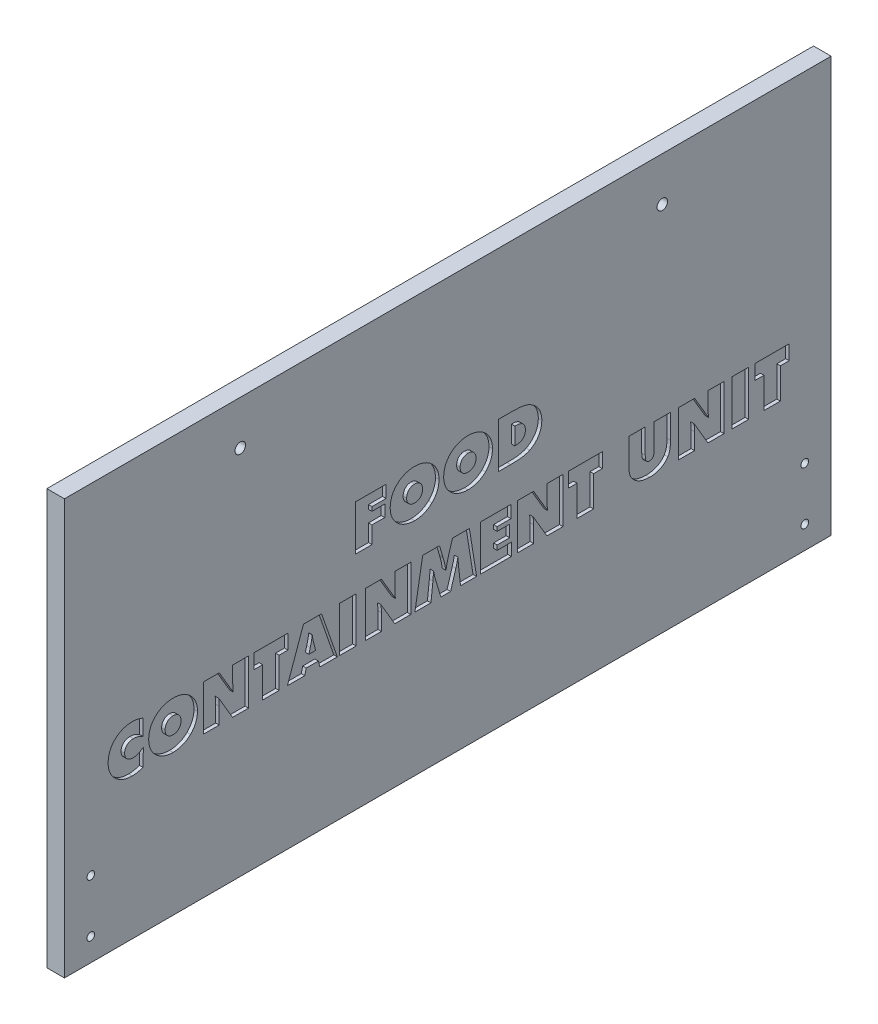
from build123d import *

# Parameters (mm, degrees)
SKETCH2_W           = 218
SKETCH2_H           = 118
BOSS_EXTRUDE1_DEPTH = 5
SKETCH15_W          = 4.678314393
SKETCH15_H          = 12.865364583
SKETCH15_W_2        = 4.678314394
CUT_EXTRUDE2_DEPTH  = 1
SKETCH16_R          = 1.5
CUT_EXTRUDE3_DEPTH  = 6
SKETCH18_R          = 1.1
CUT_EXTRUDE4_DEPTH  = 6


with BuildPart() as part:
    # Sketch2 → Boss-Extrude1 (new body)
    with BuildSketch(Plane(origin=(0, 0, 0), x_dir=(0, 0, -1), z_dir=(1, 0, 0))):
        with Locations((109, 59)):
            Rectangle(SKETCH2_W, SKETCH2_H)
    extrude(amount=-BOSS_EXTRUDE1_DEPTH)

    # Sketch15 → Cut-Extrude2 (cut)
    with BuildSketch(Plane(origin=(0, 0, 0), x_dir=(0, 0, -1), z_dir=(1, 0, 0))):
        Polygon((82.768022863, 63), (82.768022863, 75.865364583), (91.456321023, 75.865364583), (91.456321023, 72.356628788), (87.446337256, 72.356628788), (87.446337256, 71.187050189), (91.075163712, 71.187050189), (91.075163712, 67.845397051), (87.446337256, 67.845397051), (87.446337256, 63), align=None)
        with BuildLine():
            add(Edge.make_bspline(
                [(106.493760146, 69.51622362), (106.487889321, 69.286166725), (106.476319485, 68.832785682), (106.380049047, 68.165119304), (106.220241186, 67.522470312), (105.998561141, 66.905476911), (105.714845608, 66.318127193), (105.373461826, 65.761618233), (104.97359612, 65.235670347), (104.665317852, 64.917591564), (104.509653595, 64.756978564)],
                knots=[0, 0, 0, 0, 0.000689928, 0.001359664, 0.002018804, 0.002673665, 0.003322877, 0.003972109, 0.004629505, 0.00530004, 0.00530004, 0.00530004, 0.00530004], degree=3))
            add(Edge.make_bspline(
                [(104.509653595, 64.756978564), (104.343794855, 64.607146639), (104.013324874, 64.308609743), (103.463974377, 63.925256227), (102.881963855, 63.592029448), (102.263715365, 63.318769156), (101.618407496, 63.100352432), (100.948122927, 62.948680029), (100.258055409, 62.85014639), (99.79077784, 62.838701677), (99.554608551, 62.832917343)],
                knots=[0, 0, 0, 0, 0.000669981, 0.001334922, 0.002004893, 0.002679238, 0.003359506, 0.004045357, 0.004738364, 0.005446548, 0.005446548, 0.005446548, 0.005446548], degree=3))
            add(Edge.make_bspline(
                [(99.554608551, 62.832917343), (99.315825652, 62.838630414), (98.845067713, 62.849893673), (98.150668759, 62.948692446), (97.478609405, 63.100120415), (96.831806893, 63.31820776), (96.215403513, 63.594655562), (95.632456717, 63.928785339), (95.082035331, 64.316644898), (94.750519119, 64.620117589), (94.583899507, 64.772642563)],
                knots=[0, 0, 0, 0, 0.000716008, 0.001411603, 0.002099997, 0.002780265, 0.003455676, 0.00412338, 0.004793472, 0.005470567, 0.005470567, 0.005470567, 0.005470567], degree=3))
            add(Edge.make_bspline(
                [(94.583899507, 64.772642563), (94.428829669, 64.929518221), (94.121769646, 65.24015402), (93.72785182, 65.760396239), (93.38791736, 66.310103251), (93.111041023, 66.895423228), (92.892830026, 67.511043196), (92.740854373, 68.156314025), (92.642974081, 68.827499043), (92.631646879, 69.284399132), (92.625899621, 69.51622362)],
                knots=[0, 0, 0, 0, 0.000661133, 0.001309136, 0.001952553, 0.002597155, 0.003247803, 0.00390824, 0.004583146, 0.00527829, 0.00527829, 0.00527829, 0.00527829], degree=3))
            add(Edge.make_bspline(
                [(92.625899621, 69.51622362), (92.631592317, 69.748925208), (92.642791324, 70.206709502), (92.741184085, 70.879532208), (92.892686754, 71.526644383), (93.111705332, 72.14534985), (93.387077456, 72.734875153), (93.728089988, 73.28743303), (94.120185577, 73.810185112), (94.428608827, 74.119652349), (94.583899507, 74.275468676)],
                knots=[0, 0, 0, 0, 0.000697752, 0.001372658, 0.002035634, 0.002688744, 0.003338066, 0.003983708, 0.004633785, 0.005293024, 0.005293024, 0.005293024, 0.005293024], degree=3))
            add(Edge.make_bspline(
                [(94.583899507, 74.275468676), (94.749892089, 74.425941251), (95.080056817, 74.725236172), (95.625260744, 75.113248593), (96.207274967, 75.442165559), (96.823164711, 75.717705316), (97.470101698, 75.934199312), (98.14423723, 76.087892544), (98.841874393, 76.181425205), (99.315008472, 76.193443637), (99.554608551, 76.199529897)],
                knots=[0, 0, 0, 0, 0.000671693, 0.001336019, 0.002002429, 0.002674391, 0.003357134, 0.004045528, 0.004745951, 0.005464568, 0.005464568, 0.005464568, 0.005464568], degree=3))
            add(Edge.make_bspline(
                [(99.554608551, 76.199529897), (99.794212076, 76.193453274), (100.26735296, 76.181453873), (100.964940357, 76.087782046), (101.638454655, 75.934787704), (102.284718896, 75.716529065), (102.90202166, 75.442438224), (103.486782878, 75.112438687), (104.036695118, 74.72618663), (104.368985772, 74.426086802), (104.53576026, 74.275468676)],
                knots=[0, 0, 0, 0, 0.000718616, 0.001419039, 0.002107434, 0.002787702, 0.003462048, 0.00413073, 0.00479931, 0.005472974, 0.005472974, 0.005472974, 0.005472974], degree=3))
            add(Edge.make_bspline(
                [(104.53576026, 74.275468676), (104.688719178, 74.117394048), (104.992459293, 73.803495347), (105.388184874, 73.283091238), (105.722948179, 72.725894556), (106.003275883, 72.137952601), (106.223548511, 71.519585005), (106.379577438, 70.873913846), (106.47634869, 70.203151246), (106.487906659, 69.747159044), (106.493760146, 69.51622362)],
                knots=[0, 0, 0, 0, 0.000659466, 0.001309543, 0.001956061, 0.0026065, 0.003260481, 0.003921531, 0.004596438, 0.005288973, 0.005288973, 0.005288973, 0.005288973], degree=3))
        make_face()
        with BuildLine():
            add(Edge.make_bspline(
                [(99.565051217, 67.177066423), (99.647799432, 67.179219272), (99.809454138, 67.18342502), (100.045609876, 67.211937497), (100.269515412, 67.261716953), (100.48028781, 67.331866139), (100.679175719, 67.421562591), (100.865385443, 67.532176896), (101.040250116, 67.661841922), (101.199171287, 67.81263448), (101.346589751, 67.975321173), (101.471130531, 68.156127714), (101.576691739, 68.349953026), (101.665411896, 68.554893587), (101.733922226, 68.773589191), (101.780026912, 69.005573674), (101.809137906, 69.250068594), (101.813318263, 69.417805006), (101.815445752, 69.503170288)],
                knots=[0, 0, 0, 0, 0.000248233, 0.000484941, 0.000712324, 0.000935227, 0.001150207, 0.001365567, 0.00158382, 0.001801775, 0.002021831, 0.002241267, 0.002458581, 0.002683113, 0.002910181, 0.003144676, 0.003391754, 0.003647812, 0.003647812, 0.003647812, 0.003647812], degree=3))
            add(Edge.make_bspline(
                [(101.815445752, 69.503170288), (101.813314017, 69.589403162), (101.80912469, 69.75886971), (101.780060558, 70.005989775), (101.733770752, 70.240479219), (101.666191139, 70.461325604), (101.575143655, 70.667736065), (101.472863517, 70.865097807), (101.345661283, 71.046834046), (101.199229816, 71.211829059), (101.041172097, 71.36559243), (100.864509436, 71.494509154), (100.680003221, 71.608740123), (100.480219467, 71.69799943), (100.269160044, 71.767347863), (100.046009228, 71.821408202), (99.809398903, 71.848774841), (99.647780731, 71.853144212), (99.565051217, 71.855380817)],
                knots=[0, 0, 0, 0, 0.000258667, 0.000508337, 0.000745391, 0.000974952, 0.001199484, 0.001421391, 0.001640826, 0.001862841, 0.002082587, 0.002300839, 0.00251754, 0.00273252, 0.002955423, 0.00318339, 0.003420098, 0.003668331, 0.003668331, 0.003668331, 0.003668331], degree=3))
            add(Edge.make_bspline(
                [(99.565051217, 71.855380817), (99.482255189, 71.853570221), (99.320396713, 71.850030674), (99.083957409, 71.81659059), (98.859397191, 71.769322236), (98.647388151, 71.69651973), (98.446711114, 71.606975877), (98.25936681, 71.492328259), (98.084461443, 71.359270339), (97.923106465, 71.207589528), (97.775480811, 71.041394303), (97.651769645, 70.857188655), (97.542232795, 70.66361142), (97.457911313, 70.454723938), (97.384676963, 70.235953944), (97.340437113, 70.00232693), (97.310136756, 69.757202664), (97.306225016, 69.58942415), (97.304214015, 69.503170288)],
                knots=[0, 0, 0, 0, 0.000248233, 0.000485272, 0.000715204, 0.000935631, 0.001156445, 0.001373146, 0.00159297, 0.001814615, 0.002036629, 0.002258213, 0.002479073, 0.002702586, 0.002932932, 0.003169986, 0.00341447, 0.003673137, 0.003673137, 0.003673137, 0.003673137], degree=3))
            add(Edge.make_bspline(
                [(97.304214015, 69.503170288), (97.306311458, 69.417794459), (97.310432778, 69.250037323), (97.33996743, 69.005691119), (97.384618385, 68.772918264), (97.458525193, 68.556192396), (97.541551375, 68.348456487), (97.651885927, 68.156966784), (97.775520887, 67.975301399), (97.923175635, 67.811745813), (98.084529504, 67.662651083), (98.259466146, 67.532247889), (98.446789538, 67.420050858), (98.647982591, 67.33377499), (98.8593516, 67.260561667), (99.083756197, 67.212427162), (99.32061927, 67.183321352), (99.482293174, 67.179184173), (99.565051217, 67.177066423)],
                knots=[0, 0, 0, 0, 0.000256058, 0.000503136, 0.000737631, 0.000965493, 0.001189006, 0.001407586, 0.001627022, 0.001847078, 0.002066948, 0.002285201, 0.002500561, 0.002720307, 0.002940735, 0.003170666, 0.003407374, 0.003655607, 0.003655607, 0.003655607, 0.003655607], degree=3))
        make_face(mode=Mode.SUBTRACT)
        with BuildLine():
            add(Edge.make_bspline(
                [(121.698281926, 69.51622362), (121.692411102, 69.286166725), (121.680841265, 68.832785682), (121.584570828, 68.165119304), (121.424762967, 67.522470312), (121.203082922, 66.905476911), (120.919367388, 66.318127193), (120.577983606, 65.761618233), (120.1781179, 65.235670347), (119.869839633, 64.917591564), (119.714175375, 64.756978564)],
                knots=[0, 0, 0, 0, 0.000689928, 0.001359664, 0.002018804, 0.002673665, 0.003322877, 0.003972109, 0.004629505, 0.00530004, 0.00530004, 0.00530004, 0.00530004], degree=3))
            add(Edge.make_bspline(
                [(119.714175375, 64.756978564), (119.548316636, 64.607146639), (119.217846655, 64.308609743), (118.668496158, 63.925256227), (118.086485636, 63.592029448), (117.468237145, 63.318769156), (116.822929276, 63.100352432), (116.152644708, 62.948680029), (115.462577189, 62.85014639), (114.99529962, 62.838701677), (114.759130331, 62.832917343)],
                knots=[0, 0, 0, 0, 0.000669981, 0.001334922, 0.002004893, 0.002679238, 0.003359506, 0.004045357, 0.004738364, 0.005446548, 0.005446548, 0.005446548, 0.005446548], degree=3))
            add(Edge.make_bspline(
                [(114.759130331, 62.832917343), (114.520347433, 62.838630414), (114.049589493, 62.849893673), (113.355190539, 62.948692446), (112.683131186, 63.100120415), (112.036328673, 63.31820776), (111.419925293, 63.594655562), (110.836978497, 63.928785339), (110.286557112, 64.316644898), (109.955040899, 64.620117589), (109.788421287, 64.772642563)],
                knots=[0, 0, 0, 0, 0.000716008, 0.001411603, 0.002099997, 0.002780265, 0.003455676, 0.00412338, 0.004793472, 0.005470567, 0.005470567, 0.005470567, 0.005470567], degree=3))
            add(Edge.make_bspline(
                [(109.788421287, 64.772642563), (109.63335145, 64.929518221), (109.326291426, 65.24015402), (108.9323736, 65.760396239), (108.592439141, 66.310103251), (108.315562803, 66.895423228), (108.097351806, 67.511043196), (107.945376153, 68.156314025), (107.847495861, 68.827499043), (107.83616866, 69.284399132), (107.830421402, 69.51622362)],
                knots=[0, 0, 0, 0, 0.000661133, 0.001309136, 0.001952553, 0.002597155, 0.003247803, 0.00390824, 0.004583146, 0.00527829, 0.00527829, 0.00527829, 0.00527829], degree=3))
            add(Edge.make_bspline(
                [(107.830421402, 69.51622362), (107.836114097, 69.748925208), (107.847313104, 70.206709502), (107.945705865, 70.879532208), (108.097208534, 71.526644383), (108.316227113, 72.14534985), (108.591599236, 72.734875153), (108.932611769, 73.28743303), (109.324707358, 73.810185112), (109.633130607, 74.119652349), (109.788421287, 74.275468676)],
                knots=[0, 0, 0, 0, 0.000697752, 0.001372658, 0.002035634, 0.002688744, 0.003338066, 0.003983708, 0.004633785, 0.005293024, 0.005293024, 0.005293024, 0.005293024], degree=3))
            add(Edge.make_bspline(
                [(109.788421287, 74.275468676), (109.954413869, 74.425941251), (110.284578597, 74.725236172), (110.829782524, 75.113248593), (111.411796748, 75.442165559), (112.027686491, 75.717705316), (112.674623479, 75.934199312), (113.34875901, 76.087892544), (114.046396174, 76.181425205), (114.519530252, 76.193443637), (114.759130331, 76.199529897)],
                knots=[0, 0, 0, 0, 0.000671693, 0.001336019, 0.002002429, 0.002674391, 0.003357134, 0.004045528, 0.004745951, 0.005464568, 0.005464568, 0.005464568, 0.005464568], degree=3))
            add(Edge.make_bspline(
                [(114.759130331, 76.199529897), (114.998733856, 76.193453274), (115.47187474, 76.181453873), (116.169462137, 76.087782046), (116.842976435, 75.934787704), (117.489240676, 75.716529065), (118.106543441, 75.442438224), (118.691304658, 75.112438687), (119.241216898, 74.72618663), (119.573507552, 74.426086802), (119.740282041, 74.275468676)],
                knots=[0, 0, 0, 0, 0.000718616, 0.001419039, 0.002107434, 0.002787702, 0.003462048, 0.00413073, 0.00479931, 0.005472974, 0.005472974, 0.005472974, 0.005472974], degree=3))
            add(Edge.make_bspline(
                [(119.740282041, 74.275468676), (119.893240958, 74.117394048), (120.196981073, 73.803495347), (120.592706654, 73.283091238), (120.927469959, 72.725894556), (121.207797663, 72.137952601), (121.428070291, 71.519585005), (121.584099218, 70.873913846), (121.680870471, 70.203151246), (121.692428439, 69.747159044), (121.698281926, 69.51622362)],
                knots=[0, 0, 0, 0, 0.000659466, 0.001309543, 0.001956061, 0.0026065, 0.003260481, 0.003921531, 0.004596438, 0.005288973, 0.005288973, 0.005288973, 0.005288973], degree=3))
        make_face()
        with BuildLine():
            add(Edge.make_bspline(
                [(114.769572997, 67.177066423), (114.852321212, 67.179219272), (115.013975918, 67.18342502), (115.250131656, 67.211937497), (115.474037192, 67.261716953), (115.68480959, 67.331866139), (115.8836975, 67.421562591), (116.069907224, 67.532176896), (116.244771897, 67.661841922), (116.403693068, 67.81263448), (116.551111532, 67.975321173), (116.675652311, 68.156127714), (116.781213519, 68.349953026), (116.869933677, 68.554893587), (116.938444006, 68.773589191), (116.984548692, 69.005573674), (117.013659686, 69.250068594), (117.017840043, 69.417805006), (117.019967532, 69.503170288)],
                knots=[0, 0, 0, 0, 0.000248233, 0.000484941, 0.000712324, 0.000935227, 0.001150207, 0.001365567, 0.00158382, 0.001801775, 0.002021831, 0.002241267, 0.002458581, 0.002683113, 0.002910181, 0.003144676, 0.003391754, 0.003647812, 0.003647812, 0.003647812, 0.003647812], degree=3))
            add(Edge.make_bspline(
                [(117.019967532, 69.503170288), (117.017835798, 69.589403162), (117.01364647, 69.75886971), (116.984582338, 70.005989775), (116.938292532, 70.240479219), (116.87071292, 70.461325604), (116.779665436, 70.667736065), (116.677385298, 70.865097807), (116.550183063, 71.046834046), (116.403751597, 71.211829059), (116.245693877, 71.36559243), (116.069031217, 71.494509154), (115.884525002, 71.608740123), (115.684741247, 71.69799943), (115.473681824, 71.767347863), (115.250531008, 71.821408202), (115.013920683, 71.848774841), (114.852302511, 71.853144212), (114.769572997, 71.855380817)],
                knots=[0, 0, 0, 0, 0.000258667, 0.000508337, 0.000745391, 0.000974952, 0.001199484, 0.001421391, 0.001640826, 0.001862841, 0.002082587, 0.002300839, 0.00251754, 0.00273252, 0.002955423, 0.00318339, 0.003420098, 0.003668331, 0.003668331, 0.003668331, 0.003668331], degree=3))
            add(Edge.make_bspline(
                [(114.769572997, 71.855380817), (114.686776969, 71.853570221), (114.524918493, 71.850030674), (114.288479189, 71.81659059), (114.063918972, 71.769322236), (113.851909931, 71.69651973), (113.651232894, 71.606975877), (113.463888591, 71.492328259), (113.288983223, 71.359270339), (113.127628245, 71.207589528), (112.980002591, 71.041394303), (112.856291425, 70.857188655), (112.746754576, 70.66361142), (112.662433093, 70.454723938), (112.589198743, 70.235953944), (112.544958893, 70.00232693), (112.514658537, 69.757202664), (112.510746796, 69.58942415), (112.508735795, 69.503170288)],
                knots=[0, 0, 0, 0, 0.000248233, 0.000485272, 0.000715204, 0.000935631, 0.001156445, 0.001373146, 0.00159297, 0.001814615, 0.002036629, 0.002258213, 0.002479073, 0.002702586, 0.002932932, 0.003169986, 0.00341447, 0.003673137, 0.003673137, 0.003673137, 0.003673137], degree=3))
            add(Edge.make_bspline(
                [(112.508735795, 69.503170288), (112.510833239, 69.417794459), (112.514954558, 69.250037323), (112.544489211, 69.005691119), (112.589140165, 68.772918264), (112.663046973, 68.556192396), (112.746073155, 68.348456487), (112.856407707, 68.156966784), (112.980042668, 67.975301399), (113.127697415, 67.811745813), (113.289051284, 67.662651083), (113.463987926, 67.532247889), (113.651311319, 67.420050858), (113.852504371, 67.33377499), (114.06387338, 67.260561667), (114.288277977, 67.212427162), (114.52514105, 67.183321352), (114.686814954, 67.179184173), (114.769572997, 67.177066423)],
                knots=[0, 0, 0, 0, 0.000256058, 0.000503136, 0.000737631, 0.000965493, 0.001189006, 0.001407586, 0.001627022, 0.001847078, 0.002066948, 0.002285201, 0.002500561, 0.002720307, 0.002940735, 0.003170666, 0.003407374, 0.003655607, 0.003655607, 0.003655607, 0.003655607], degree=3))
        make_face(mode=Mode.SUBTRACT)
        with BuildLine():
            Line((123.369108496, 63), (123.369108496, 75.865364583))
            Line((123.369108496, 75.865364583), (127.18590294, 75.865364583))
            add(Edge.make_bspline(
                [(127.18590294, 75.865364583), (127.472241498, 75.862781969), (128.023410201, 75.857810736), (128.81770109, 75.822292351), (129.546629394, 75.759986173), (130.211805001, 75.675992058), (130.815267125, 75.564260768), (131.359465221, 75.427781504), (131.846709674, 75.263825378), (132.14123951, 75.12321947), (132.281923976, 75.056057964)],
                knots=[0, 0, 0, 0, 0.000859008, 0.001653492, 0.002384558, 0.00305324, 0.003664097, 0.004224467, 0.004735525, 0.005202863, 0.005202863, 0.005202863, 0.005202863], degree=3))
            add(Edge.make_bspline(
                [(132.281923976, 75.056057964), (132.4179073, 74.982223316), (132.687150158, 74.836032953), (133.066847325, 74.586813977), (133.424030295, 74.321612714), (133.758892842, 74.04183022), (134.065127901, 73.738176885), (134.349923761, 73.421086053), (134.610398963, 73.084597238), (134.844053733, 72.730553213), (135.053088705, 72.361516076), (135.23793027, 71.980758784), (135.38713655, 71.583547005), (135.517564236, 71.177702657), (135.612883307, 70.756305923), (135.683489374, 70.323989906), (135.726499349, 69.878239871), (135.730964595, 69.577233576), (135.733225108, 69.424850292)],
                knots=[0, 0, 0, 0, 0.000464038, 0.000918782, 0.001361033, 0.001798256, 0.002226548, 0.002653654, 0.003076106, 0.003501861, 0.003925087, 0.004347789, 0.00477008, 0.005196962, 0.005625692, 0.006064757, 0.006510532, 0.006967585, 0.006967585, 0.006967585, 0.006967585], degree=3))
            add(Edge.make_bspline(
                [(135.733225108, 69.424850292), (135.730915304, 69.273341462), (135.726339757, 68.97321394), (135.683945147, 68.529995561), (135.612438699, 68.099525378), (135.517142437, 67.681129045), (135.390767011, 67.275922579), (135.239014132, 66.882185793), (135.059660341, 66.501019671), (134.849046373, 66.134831562), (134.614833455, 65.783070462), (134.355947801, 65.447068468), (134.06952298, 65.131364076), (133.761773446, 64.830374554), (133.428093154, 64.547490471), (133.070154058, 64.280946842), (132.686388105, 64.032316916), (132.416043936, 63.884212602), (132.27931331, 63.809306619)],
                knots=[0, 0, 0, 0, 0.000454443, 0.000900218, 0.001334131, 0.001762861, 0.002186473, 0.002606328, 0.003027908, 0.003448866, 0.003872446, 0.004294898, 0.00472006, 0.005150219, 0.005585449, 0.006031353, 0.006488287, 0.006955881, 0.006955881, 0.006955881, 0.006955881], degree=3))
            add(Edge.make_bspline(
                [(132.27931331, 63.809306619), (132.135104039, 63.741382575), (131.834198887, 63.599653163), (131.339803238, 63.431953566), (130.790617236, 63.297119597), (130.297181582, 63.203517375), (129.868436708, 63.146310453), (129.514117047, 63.107752372), (129.132996416, 63.072860209), (128.725395701, 63.049364597), (128.292240414, 63.022687579), (127.831612814, 63.013337529), (127.344352542, 63.000308266), (127.010129602, 63.000104517), (126.838684293, 63)],
                knots=[0, 0, 0, 0, 0.00047793, 0.000997243, 0.001562674, 0.002173531, 0.002502868, 0.002860072, 0.003242737, 0.003650837, 0.004084844, 0.004544507, 0.005032813, 0.005547121, 0.005547121, 0.005547121, 0.005547121], degree=3))
            Line((126.838684293, 63), (123.369108496, 63))
        make_face()
        with BuildLine():
            add(Edge.make_bspline(
                [(128.04742289, 67.009983766), (128.173660716, 67.012058077), (128.417774984, 67.016069305), (128.770031796, 67.044700451), (129.096212347, 67.091448371), (129.395936531, 67.1553066), (129.670272348, 67.239206133), (129.917711719, 67.340298438), (130.141047459, 67.457357722), (130.335503526, 67.597694047), (130.507758947, 67.755230624), (130.655330309, 67.934572143), (130.778224085, 68.13557123), (130.881023719, 68.355930339), (130.95824553, 68.598394619), (131.015574119, 68.859586343), (131.05010364, 69.141975459), (131.053269315, 69.336857516), (131.054910714, 69.437903625)],
                knots=[0, 0, 0, 0, 0.000378691, 0.000732299, 0.001059414, 0.001366653, 0.001650724, 0.001918823, 0.002167605, 0.002405233, 0.00263617, 0.002866146, 0.003099432, 0.003341211, 0.00359384, 0.00386115, 0.004142545, 0.004445562, 0.004445562, 0.004445562, 0.004445562], degree=3))
            add(Edge.make_bspline(
                [(131.054910714, 69.437903625), (131.053348586, 69.536365196), (131.050311044, 69.727822717), (131.014225824, 70.004290151), (130.964046343, 70.262809396), (130.888275495, 70.502199488), (130.788343625, 70.721060493), (130.671450994, 70.922940433), (130.528129035, 71.101436971), (130.365041612, 71.261546232), (130.18089414, 71.405533225), (129.969423384, 71.523088189), (129.739961732, 71.629157358), (129.485673598, 71.712266804), (129.208677625, 71.776581561), (128.908578752, 71.823635654), (128.585635856, 71.848415915), (128.363351627, 71.853007333), (128.248444211, 71.855380817)],
                knots=[0, 0, 0, 0, 0.00029519, 0.000573994, 0.000835113, 0.001084456, 0.001325147, 0.00155573, 0.001782422, 0.00200949, 0.002240294, 0.002481212, 0.002733571, 0.002997752, 0.003282075, 0.003585957, 0.003908128, 0.004252894, 0.004252894, 0.004252894, 0.004252894], degree=3))
            Line((128.248444211, 71.855380817), (128.04742289, 71.855380817))
            Line((128.04742289, 71.855380817), (128.04742289, 67.009983766))
        make_face(mode=Mode.SUBTRACT)
        with BuildLine():
            add(Edge.make_bspline(
                [(22.354589051, 48.299222132), (22.248246742, 48.365627095), (22.038213511, 48.496781375), (21.714937126, 48.671384779), (21.383814511, 48.810454554), (21.051595398, 48.929960165), (20.712096428, 49.022122054), (20.364627057, 49.08673718), (20.007696444, 49.127399347), (19.766657494, 49.132204511), (19.644717209, 49.134635417)],
                knots=[0, 0, 0, 0, 0.000376099, 0.000742821, 0.001100701, 0.001452454, 0.001801406, 0.002154705, 0.002511909, 0.002877635, 0.002877635, 0.002877635, 0.002877635], degree=3))
            add(Edge.make_bspline(
                [(19.644717209, 49.134635417), (19.551554917, 49.132375268), (19.369131123, 49.127949606), (19.102206572, 49.100844672), (18.850393444, 49.046803371), (18.611157915, 48.977522782), (18.386888854, 48.885496266), (18.174748168, 48.775833033), (17.97979781, 48.641891065), (17.798605625, 48.489932706), (17.635730266, 48.322062655), (17.49236725, 48.13963222), (17.371853401, 47.943622274), (17.275278226, 47.732794977), (17.199195496, 47.509716217), (17.144710803, 47.272708824), (17.109634623, 47.022785987), (17.106255656, 46.851292004), (17.10453869, 46.764150222)],
                knots=[0, 0, 0, 0, 0.000279536, 0.000547368, 0.000803374, 0.001051181, 0.001293579, 0.001529466, 0.001766246, 0.002001568, 0.002237888, 0.00246663, 0.002696325, 0.002926434, 0.0031609, 0.003402172, 0.003655083, 0.003916358, 0.003916358, 0.003916358, 0.003916358], degree=3))
            add(Edge.make_bspline(
                [(17.10453869, 46.764150222), (17.106447159, 46.678768529), (17.110180222, 46.511757596), (17.142207996, 46.26787404), (17.194081819, 46.036966693), (17.267117288, 45.818844862), (17.362192663, 45.614869006), (17.474170032, 45.421489784), (17.611530869, 45.243917949), (17.767164364, 45.080167833), (17.940592618, 44.933368358), (18.128880162, 44.804223047), (18.334045957, 44.698197061), (18.551076234, 44.608181864), (18.782531075, 44.541385171), (19.026747398, 44.490819609), (19.286400228, 44.462698884), (19.464517336, 44.458484497), (19.555954548, 44.456321023)],
                knots=[0, 0, 0, 0, 0.000256058, 0.000500863, 0.00073646, 0.000965143, 0.001189418, 0.001410602, 0.001634084, 0.001861212, 0.002087182, 0.00231455, 0.0025446, 0.002778761, 0.003018317, 0.003266124, 0.003526171, 0.00380049, 0.00380049, 0.00380049, 0.00380049], degree=3))
            add(Edge.make_bspline(
                [(19.555954548, 44.456321023), (19.669283681, 44.460060082), (19.897969866, 44.467605106), (20.241385494, 44.522679101), (20.587933637, 44.608195996), (20.937996786, 44.734489155), (21.299181506, 44.893680613), (21.669323333, 45.101990395), (22.059724229, 45.343302653), (22.317439379, 45.529348778), (22.451183712, 45.625899621)],
                knots=[0, 0, 0, 0, 0.000339878, 0.000685838, 0.001041052, 0.001409314, 0.001800826, 0.002223787, 0.002682329, 0.003177021, 0.003177021, 0.003177021, 0.003177021], degree=3))
            Line((22.451183712, 45.625899621), (22.299765054, 40.738731906))
            add(Edge.make_bspline(
                [(22.299765054, 40.738731906), (22.049092134, 40.642195661), (21.554965267, 40.451903259), (20.793082723, 40.258989711), (20.032586726, 40.134869089), (19.524228748, 40.119710978), (19.271391897, 40.112171943)],
                knots=[0, 0, 0, 0, 0.000805191, 0.001587193, 0.002353347, 0.003111452, 0.003111452, 0.003111452, 0.003111452], degree=3))
            add(Edge.make_bspline(
                [(19.271391897, 40.112171943), (19.116408474, 40.114642057), (18.808555298, 40.119548599), (18.350909576, 40.160071973), (17.901027714, 40.224846588), (17.461836996, 40.316270844), (17.036672591, 40.429599436), (16.633099853, 40.569205348), (16.247638795, 40.724116621), (16.005430726, 40.84908401), (15.885357428, 40.911035896)],
                knots=[0, 0, 0, 0, 0.000464882, 0.000923424, 0.001377177, 0.001827742, 0.002268512, 0.002696167, 0.003108256, 0.003513389, 0.003513389, 0.003513389, 0.003513389], degree=3))
            add(Edge.make_bspline(
                [(15.885357428, 40.911035896), (15.745693492, 40.992546456), (15.470441282, 41.153188942), (15.085233779, 41.426124021), (14.719557336, 41.705358748), (14.385524542, 42.008443162), (14.073733338, 42.323570851), (13.788564745, 42.656019431), (13.529287717, 43.003942663), (13.296540255, 43.367822932), (13.089261741, 43.746666604), (12.912571497, 44.140808877), (12.762735184, 44.548252089), (12.640250411, 44.969642947), (12.543355165, 45.404676874), (12.476513399, 45.854008027), (12.432774765, 46.315983988), (12.428425303, 46.629164198), (12.426224297, 46.78764622)],
                knots=[0, 0, 0, 0, 0.000484889, 0.000955627, 0.001415171, 0.001864396, 0.002307456, 0.002744382, 0.003177233, 0.003608128, 0.004039212, 0.004471551, 0.004902699, 0.00534056, 0.005787114, 0.006238668, 0.00670264, 0.007177961, 0.007177961, 0.007177961, 0.007177961], degree=3))
            add(Edge.make_bspline(
                [(12.426224297, 46.78764622), (12.43198023, 47.021205681), (12.443325407, 47.481560768), (12.541098424, 48.157983471), (12.693637526, 48.809098562), (12.911062022, 49.43194351), (13.188778651, 50.023993864), (13.523551978, 50.58195946), (13.916905429, 51.103624501), (14.219040157, 51.417544036), (14.37117085, 51.575608608)],
                knots=[0, 0, 0, 0, 0.00070036, 0.001380437, 0.002045952, 0.00270399, 0.003355675, 0.004004429, 0.004652926, 0.005310617, 0.005310617, 0.005310617, 0.005310617], degree=3))
            add(Edge.make_bspline(
                [(14.37117085, 51.575608608), (14.534223972, 51.726475817), (14.859075706, 52.027049482), (15.402056154, 52.409528388), (15.978723349, 52.738334099), (16.592488348, 53.007297161), (17.23777934, 53.218520642), (17.910712753, 53.370033642), (18.610184747, 53.460183178), (19.084900007, 53.472515504), (19.326215894, 53.478784497)],
                knots=[0, 0, 0, 0, 0.000665807, 0.001326491, 0.001987072, 0.002654531, 0.003333153, 0.004020969, 0.004721056, 0.005444889, 0.005444889, 0.005444889, 0.005444889], degree=3))
            add(Edge.make_bspline(
                [(19.326215894, 53.478784497), (19.45681437, 53.4768177), (19.716646937, 53.472904654), (20.105301014, 53.440059856), (20.490571597, 53.3885654), (20.873111265, 53.314931157), (21.251373274, 53.221017402), (21.625787412, 53.106544301), (21.99375021, 52.967608154), (22.234106553, 52.861188016), (22.354589051, 52.807843203)],
                knots=[0, 0, 0, 0, 0.000391739, 0.000779386, 0.001169276, 0.00155738, 0.001947419, 0.002338017, 0.002731267, 0.003126514, 0.003126514, 0.003126514, 0.003126514], degree=3))
            Line((22.354589051, 52.807843203), (22.354589051, 48.299222132))
        make_face()
        with BuildLine():
            add(Edge.make_bspline(
                [(37.822788149, 46.79547822), (37.816917325, 46.565421324), (37.805347488, 46.112040282), (37.709077051, 45.444373903), (37.549269189, 44.801724911), (37.327589145, 44.184731511), (37.043873611, 43.597381792), (36.702489829, 43.040872833), (36.302624123, 42.514924946), (35.994345855, 42.196846164), (35.838681598, 42.036233164)],
                knots=[0, 0, 0, 0, 0.000689928, 0.001359664, 0.002018804, 0.002673665, 0.003322877, 0.003972109, 0.004629505, 0.00530004, 0.00530004, 0.00530004, 0.00530004], degree=3))
            add(Edge.make_bspline(
                [(35.838681598, 42.036233164), (35.672822858, 41.886401239), (35.342352878, 41.587864342), (34.79300238, 41.204510827), (34.210991859, 40.871284047), (33.592743368, 40.598023755), (32.947435499, 40.379607031), (32.27715093, 40.227934628), (31.587083412, 40.129400989), (31.119805843, 40.117956277), (30.883636554, 40.112171943)],
                knots=[0, 0, 0, 0, 0.000669981, 0.001334922, 0.002004893, 0.002679238, 0.003359506, 0.004045357, 0.004738364, 0.005446548, 0.005446548, 0.005446548, 0.005446548], degree=3))
            add(Edge.make_bspline(
                [(30.883636554, 40.112171943), (30.644853656, 40.117885014), (30.174095716, 40.129148273), (29.479696762, 40.227947046), (28.807637408, 40.379375014), (28.160834896, 40.597462359), (27.544431516, 40.873910162), (26.96148472, 41.208039938), (26.411063334, 41.595899498), (26.079547122, 41.899372188), (25.91292751, 42.051897163)],
                knots=[0, 0, 0, 0, 0.000716008, 0.001411603, 0.002099997, 0.002780265, 0.003455676, 0.00412338, 0.004793472, 0.005470567, 0.005470567, 0.005470567, 0.005470567], degree=3))
            add(Edge.make_bspline(
                [(25.91292751, 42.051897163), (25.757857673, 42.20877282), (25.450797649, 42.51940862), (25.056879823, 43.039650839), (24.716945364, 43.589357851), (24.440069026, 44.174677828), (24.221858029, 44.790297796), (24.069882376, 45.435568624), (23.972002084, 46.106753643), (23.960674882, 46.563653732), (23.954927624, 46.79547822)],
                knots=[0, 0, 0, 0, 0.000661133, 0.001309136, 0.001952553, 0.002597155, 0.003247803, 0.00390824, 0.004583146, 0.00527829, 0.00527829, 0.00527829, 0.00527829], degree=3))
            add(Edge.make_bspline(
                [(23.954927624, 46.79547822), (23.96062032, 47.028179807), (23.971819327, 47.485964102), (24.070212088, 48.158786808), (24.221714757, 48.805898982), (24.440733336, 49.42460445), (24.716105459, 50.014129753), (25.057117992, 50.566687629), (25.449213581, 51.089439711), (25.75763683, 51.398906948), (25.91292751, 51.554723276)],
                knots=[0, 0, 0, 0, 0.000697752, 0.001372658, 0.002035634, 0.002688744, 0.003338066, 0.003983708, 0.004633785, 0.005293024, 0.005293024, 0.005293024, 0.005293024], degree=3))
            add(Edge.make_bspline(
                [(25.91292751, 51.554723276), (26.078920092, 51.705195851), (26.40908482, 52.004490772), (26.954288747, 52.392503193), (27.536302971, 52.721420158), (28.152192714, 52.996959916), (28.799129702, 53.213453912), (29.473265233, 53.367147144), (30.170902396, 53.460679805), (30.644036475, 53.472698236), (30.883636554, 53.478784497)],
                knots=[0, 0, 0, 0, 0.000671693, 0.001336019, 0.002002429, 0.002674391, 0.003357134, 0.004045528, 0.004745951, 0.005464568, 0.005464568, 0.005464568, 0.005464568], degree=3))
            add(Edge.make_bspline(
                [(30.883636554, 53.478784497), (31.123240079, 53.472707874), (31.596380963, 53.460708473), (32.29396836, 53.367036645), (32.967482658, 53.214042303), (33.613746899, 52.995783665), (34.231049664, 52.721692824), (34.815810881, 52.391693287), (35.365723121, 52.00544123), (35.698013775, 51.705341401), (35.864788263, 51.554723276)],
                knots=[0, 0, 0, 0, 0.000718616, 0.001419039, 0.002107434, 0.002787702, 0.003462048, 0.00413073, 0.00479931, 0.005472974, 0.005472974, 0.005472974, 0.005472974], degree=3))
            add(Edge.make_bspline(
                [(35.864788263, 51.554723276), (36.017747181, 51.396648648), (36.321487296, 51.082749947), (36.717212877, 50.562345838), (37.051976182, 50.005149156), (37.332303886, 49.417207201), (37.552576514, 48.798839605), (37.708605441, 48.153168445), (37.805376694, 47.482405846), (37.816934662, 47.026413644), (37.822788149, 46.79547822)],
                knots=[0, 0, 0, 0, 0.000659466, 0.001309543, 0.001956061, 0.0026065, 0.003260481, 0.003921531, 0.004596438, 0.005288973, 0.005288973, 0.005288973, 0.005288973], degree=3))
        make_face()
        with BuildLine():
            add(Edge.make_bspline(
                [(30.89407922, 44.456321023), (30.976827435, 44.458473872), (31.138482141, 44.46267962), (31.374637879, 44.491192097), (31.598543415, 44.540971553), (31.809315813, 44.611120739), (32.008203723, 44.70081719), (32.194413446, 44.811431495), (32.36927812, 44.941096521), (32.528199291, 45.09188908), (32.675617755, 45.254575773), (32.800158534, 45.435382314), (32.905719742, 45.629207626), (32.9944399, 45.834148186), (33.062950229, 46.052843791), (33.109054915, 46.284828273), (33.138165909, 46.529323193), (33.142346266, 46.697059606), (33.144473755, 46.782424887)],
                knots=[0, 0, 0, 0, 0.000248233, 0.000484941, 0.000712324, 0.000935227, 0.001150207, 0.001365567, 0.00158382, 0.001801775, 0.002021831, 0.002241267, 0.002458581, 0.002683113, 0.002910181, 0.003144676, 0.003391754, 0.003647812, 0.003647812, 0.003647812, 0.003647812], degree=3))
            add(Edge.make_bspline(
                [(33.144473755, 46.782424887), (33.14234202, 46.868657761), (33.138152693, 47.03812431), (33.109088561, 47.285244375), (33.062798755, 47.519733818), (32.995219143, 47.740580204), (32.904171659, 47.946990665), (32.801891521, 48.144352407), (32.674689286, 48.326088645), (32.52825782, 48.491083659), (32.3702001, 48.644847029), (32.19353744, 48.773763754), (32.009031225, 48.887994723), (31.80924747, 48.97725403), (31.598188047, 49.046602462), (31.375037231, 49.100662802), (31.138426906, 49.12802944), (30.976808734, 49.132398812), (30.89407922, 49.134635417)],
                knots=[0, 0, 0, 0, 0.000258667, 0.000508337, 0.000745391, 0.000974952, 0.001199484, 0.001421391, 0.001640826, 0.001862841, 0.002082587, 0.002300839, 0.00251754, 0.00273252, 0.002955423, 0.00318339, 0.003420098, 0.003668331, 0.003668331, 0.003668331, 0.003668331], degree=3))
            add(Edge.make_bspline(
                [(30.89407922, 49.134635417), (30.811283192, 49.13282482), (30.649424716, 49.129285274), (30.412985412, 49.09584519), (30.188425195, 49.048576836), (29.976416154, 48.97577433), (29.775739117, 48.886230477), (29.588394814, 48.771582859), (29.413489446, 48.638524939), (29.252134468, 48.486844128), (29.104508814, 48.320648903), (28.980797648, 48.136443254), (28.871260799, 47.94286602), (28.786939316, 47.733978538), (28.713704966, 47.515208544), (28.669465116, 47.28158153), (28.63916476, 47.036457264), (28.635253019, 46.86867875), (28.633242018, 46.782424887)],
                knots=[0, 0, 0, 0, 0.000248233, 0.000485272, 0.000715204, 0.000935631, 0.001156445, 0.001373146, 0.00159297, 0.001814615, 0.002036629, 0.002258213, 0.002479073, 0.002702586, 0.002932932, 0.003169986, 0.00341447, 0.003673137, 0.003673137, 0.003673137, 0.003673137], degree=3))
            add(Edge.make_bspline(
                [(28.633242018, 46.782424887), (28.635339462, 46.697049059), (28.639460781, 46.529291923), (28.668995433, 46.284945719), (28.713646388, 46.052172864), (28.787553196, 45.835446995), (28.870579378, 45.627711086), (28.98091393, 45.436221383), (29.104548891, 45.254555999), (29.252203638, 45.091000412), (29.413557507, 44.941905683), (29.588494149, 44.811502489), (29.775817541, 44.699305458), (29.977010594, 44.613029589), (30.188379603, 44.539816266), (30.4127842, 44.491681761), (30.649647273, 44.462575952), (30.811321177, 44.458438772), (30.89407922, 44.456321023)],
                knots=[0, 0, 0, 0, 0.000256058, 0.000503136, 0.000737631, 0.000965493, 0.001189006, 0.001407586, 0.001627022, 0.001847078, 0.002066948, 0.002285201, 0.002500561, 0.002720307, 0.002940735, 0.003170666, 0.003407374, 0.003655607, 0.003655607, 0.003655607, 0.003655607], degree=3))
        make_face(mode=Mode.SUBTRACT)
        with BuildLine():
            Line((39.493614719, 40.2792546), (39.493614719, 53.144619183))
            Line((39.493614719, 53.144619183), (44.010067789, 53.144619183))
            Line((44.010067789, 53.144619183), (47.991334223, 46.414320909))
            add(Edge.make_bspline(
                [(47.991334223, 46.414320909), (47.966862241, 46.571594269), (47.915660964, 46.900648), (47.880805628, 47.330149148), (47.865054336, 47.713487973), (47.853971323, 48.048525099), (47.849874248, 48.425395302), (47.848480886, 48.689952092), (47.847747565, 48.829187434)],
                knots=[0, 0, 0, 0, 0.000477381, 0.000998796, 0.001291482, 0.00162842, 0.002004392, 0.002422107, 0.002422107, 0.002422107, 0.002422107], degree=3))
            Line((47.847747565, 48.829187434), (47.847747565, 53.144619183))
            Line((47.847747565, 53.144619183), (52.358979302, 53.144619183))
            Line((52.358979302, 53.144619183), (52.358979302, 40.2792546))
            Line((52.358979302, 40.2792546), (47.805976901, 40.2792546))
            Line((47.805976901, 40.2792546), (43.863870464, 46.957339544))
            add(Edge.make_bspline(
                [(43.863870464, 46.957339544), (43.886570385, 46.808743502), (43.933550154, 46.501209051), (43.970541774, 46.016187966), (44.003082257, 45.485362346), (44.004236974, 45.114275505), (44.004846456, 44.918408996)],
                knots=[0, 0, 0, 0, 0.000450799, 0.000932975, 0.001458504, 0.002045956, 0.002045956, 0.002045956, 0.002045956], degree=3))
            Line((44.004846456, 44.918408996), (44.004846456, 40.2792546))
            Line((44.004846456, 40.2792546), (39.493614719, 40.2792546))
        make_face()
        Polygon((56.368963068, 40.2792546), (56.368963068, 48.96755276), (53.862723214, 48.96755276), (53.862723214, 53.144619183), (63.553517316, 53.144619183), (63.553517316, 48.96755276), (61.047277462, 48.96755276), (61.047277462, 40.2792546), align=None)
        Polygon((63.386434659, 40.2792546), (67.962933059, 53.144619183), (73.100724759, 53.144619183), (77.588460498, 40.2792546), (72.62819412, 40.2792546), (72.215708811, 41.950081169), (68.735690347, 41.950081169), (68.341479704, 40.2792546), align=None)
        with BuildLine():
            Line((69.505836969, 44.957568994), (71.427287524, 44.957568994))
            Line((71.427287524, 44.957568994), (71.030466213, 46.416931575))
            add(Edge.make_bspline(
                [(71.030466213, 46.416931575), (70.985469302, 46.590824753), (70.901237578, 46.916343142), (70.792326174, 47.374491992), (70.701138302, 47.76703605), (70.61917472, 48.20091468), (70.547207861, 48.685387926), (70.519238904, 49.062186562), (70.505722244, 49.24428341)],
                knots=[0, 0, 0, 0, 0.000538842, 0.001008682, 0.001412762, 0.00174762, 0.002333178, 0.002880827, 0.002880827, 0.002880827, 0.002880827], degree=3))
            Line((70.505722244, 49.24428341), (70.427402249, 49.24428341))
            add(Edge.make_bspline(
                [(70.427402249, 49.24428341), (70.414165451, 49.062145567), (70.38676645, 48.685136332), (70.310859688, 48.201112188), (70.229501593, 47.767017589), (70.138144998, 47.374498238), (70.02928952, 46.916341199), (69.945049146, 46.590824077), (69.900047613, 46.416931575)],
                knots=[0, 0, 0, 0, 0.000547649, 0.001133585, 0.001468443, 0.001872524, 0.002342364, 0.002881206, 0.002881206, 0.002881206, 0.002881206], degree=3))
            Line((69.900047613, 46.416931575), (69.505836969, 44.957568994))
        make_face(mode=Mode.SUBTRACT)
        with Locations((80.595948323, 46.711936892)):
            Rectangle(SKETCH15_W, SKETCH15_H)
        with BuildLine():
            Line((85.60842803, 40.2792546), (85.60842803, 53.144619183))
            Line((85.60842803, 53.144619183), (90.1248811, 53.144619183))
            Line((90.1248811, 53.144619183), (94.106147535, 46.414320909))
            add(Edge.make_bspline(
                [(94.106147535, 46.414320909), (94.081675553, 46.571594269), (94.030474275, 46.900648), (93.99561894, 47.330149148), (93.979867648, 47.713487973), (93.968784635, 48.048525099), (93.964687559, 48.425395302), (93.963294198, 48.689952092), (93.962560877, 48.829187434)],
                knots=[0, 0, 0, 0, 0.000477381, 0.000998796, 0.001291482, 0.00162842, 0.002004392, 0.002422107, 0.002422107, 0.002422107, 0.002422107], degree=3))
            Line((93.962560877, 48.829187434), (93.962560877, 53.144619183))
            Line((93.962560877, 53.144619183), (98.473792614, 53.144619183))
            Line((98.473792614, 53.144619183), (98.473792614, 40.2792546))
            Line((98.473792614, 40.2792546), (93.920790212, 40.2792546))
            Line((93.920790212, 40.2792546), (89.978683776, 46.957339544))
            add(Edge.make_bspline(
                [(89.978683776, 46.957339544), (90.001383697, 46.808743502), (90.048363466, 46.501209051), (90.085355086, 46.016187966), (90.117895569, 45.485362346), (90.119050286, 45.114275505), (90.119659767, 44.918408996)],
                knots=[0, 0, 0, 0, 0.000450799, 0.000932975, 0.001458504, 0.002045956, 0.002045956, 0.002045956, 0.002045956], degree=3))
            Line((90.119659767, 44.918408996), (90.119659767, 40.2792546))
            Line((90.119659767, 40.2792546), (85.60842803, 40.2792546))
        make_face()
        with BuildLine():
            Line((112.626215789, 40.2792546), (112.059701155, 45.375275636))
            add(Edge.make_bspline(
                [(112.059701155, 45.375275636), (112.04269442, 45.571111929), (112.00874908, 45.961999983), (111.950676577, 46.547927286), (111.904221878, 47.13457576), (111.879077773, 47.526431989), (111.866511833, 47.722264832)],
                knots=[0, 0, 0, 0, 0.000589716, 0.00117707, 0.001766346, 0.00235505, 0.00235505, 0.00235505, 0.00235505], degree=3))
            add(Edge.make_bspline(
                [(111.866511833, 47.722264832), (111.837206665, 47.532183564), (111.77642459, 47.13793453), (111.641620836, 46.533737697), (111.480354506, 45.890798704), (111.351220348, 45.453153256), (111.2843332, 45.226467644)],
                knots=[0, 0, 0, 0, 0.000576833, 0.001196414, 0.00185619, 0.002565148, 0.002565148, 0.002565148, 0.002565148], degree=3))
            Line((111.2843332, 45.226467644), (109.798863953, 40.2792546))
            Line((109.798863953, 40.2792546), (107.031557448, 40.2792546))
            Line((107.031557448, 40.2792546), (105.546088201, 45.226467644))
            add(Edge.make_bspline(
                [(105.546088201, 45.226467644), (105.477194234, 45.453061039), (105.344317396, 45.890095152), (105.182022407, 46.533064342), (105.055423429, 47.138597951), (104.993696936, 47.532283776), (104.963909569, 47.722264832)],
                knots=[0, 0, 0, 0, 0.000710418, 0.001370194, 0.001988696, 0.002565529, 0.002565529, 0.002565529, 0.002565529], degree=3))
            add(Edge.make_bspline(
                [(104.963909569, 47.722264832), (104.949727478, 47.524675243), (104.921539691, 47.131953669), (104.868579584, 46.545907388), (104.824318927, 45.96067094), (104.788643652, 45.571031902), (104.770720247, 45.375275636)],
                knots=[0, 0, 0, 0, 0.000594281, 0.00118117, 0.001765242, 0.002354958, 0.002354958, 0.002354958, 0.002354958], degree=3))
            Line((104.770720247, 45.375275636), (104.204205613, 40.2792546))
            Line((104.204205613, 40.2792546), (99.643371212, 40.2792546))
            Line((99.643371212, 40.2792546), (101.851995083, 53.144619183))
            Line((101.851995083, 53.144619183), (106.653010803, 53.144619183))
            Line((106.653010803, 53.144619183), (107.571965417, 49.962216702))
            add(Edge.make_bspline(
                [(107.571965417, 49.962216702), (107.580881783, 49.934433065), (107.600574987, 49.873068513), (107.628101289, 49.76951897), (107.665445872, 49.648174267), (107.691292947, 49.560205468), (107.705109409, 49.513182061)],
                knots=[0, 0, 0, 0, 8.7525e-05, 0.000193314, 0.000321343, 0.000468377, 0.000468377, 0.000468377, 0.000468377], degree=3))
            add(Edge.make_bspline(
                [(107.705109409, 49.513182061), (107.751672781, 49.349704048), (107.842645036, 49.030312158), (107.968202728, 48.561478631), (108.077938262, 48.113899311), (108.174154122, 47.689095715), (108.259431449, 47.286581153), (108.325936512, 46.905778733), (108.383223665, 46.547552095), (108.408301095, 46.315236913), (108.420432034, 46.202856921)],
                knots=[0, 0, 0, 0, 0.000509936, 0.000996277, 0.00145597, 0.001892334, 0.002302964, 0.002690118, 0.003051957, 0.003391002, 0.003391002, 0.003391002, 0.003391002], degree=3))
            Line((108.420432034, 46.202856921), (108.498752029, 46.202856921))
            add(Edge.make_bspline(
                [(108.498752029, 46.202856921), (108.540331045, 46.484422422), (108.626447886, 47.06758994), (108.782406777, 47.804037262), (108.933140488, 48.428423315), (109.066929615, 48.932836001), (109.214545618, 49.467213459), (109.326268516, 49.830216862), (109.383767978, 50.017040699)],
                knots=[0, 0, 0, 0, 0.000853692, 0.001768134, 0.002256963, 0.002780641, 0.003333616, 0.003919999, 0.003919999, 0.003919999, 0.003919999], degree=3))
            Line((109.383767978, 50.017040699), (110.347103921, 53.144619183))
            Line((110.347103921, 53.144619183), (115.137676976, 53.144619183))
            Line((115.137676976, 53.144619183), (117.187050189, 40.2792546))
            Line((117.187050189, 40.2792546), (112.626215789, 40.2792546))
        make_face()
        Polygon((118.356628788, 40.2792546), (118.356628788, 53.144619183), (126.943110954, 53.144619183), (126.943110954, 49.635883387), (123.034943182, 49.635883387), (123.034943182, 48.466304789), (126.580228308, 48.466304789), (126.580228308, 45.12465165), (123.034943182, 45.12465165), (123.034943182, 43.787990395), (127.044926948, 43.787990395), (127.044926948, 40.2792546), align=None)
        with BuildLine():
            Line((128.882836174, 40.2792546), (128.882836174, 53.144619183))
            Line((128.882836174, 53.144619183), (133.399289244, 53.144619183))
            Line((133.399289244, 53.144619183), (137.380555679, 46.414320909))
            add(Edge.make_bspline(
                [(137.380555679, 46.414320909), (137.356083697, 46.571594269), (137.304882419, 46.900648), (137.270027084, 47.330149148), (137.254275792, 47.713487973), (137.243192779, 48.048525099), (137.239095703, 48.425395302), (137.237702342, 48.689952092), (137.236969021, 48.829187434)],
                knots=[0, 0, 0, 0, 0.000477381, 0.000998796, 0.001291482, 0.00162842, 0.002004392, 0.002422107, 0.002422107, 0.002422107, 0.002422107], degree=3))
            Line((137.236969021, 48.829187434), (137.236969021, 53.144619183))
            Line((137.236969021, 53.144619183), (141.748200758, 53.144619183))
            Line((141.748200758, 53.144619183), (141.748200758, 40.2792546))
            Line((141.748200758, 40.2792546), (137.195198356, 40.2792546))
            Line((137.195198356, 40.2792546), (133.253091919, 46.957339544))
            add(Edge.make_bspline(
                [(133.253091919, 46.957339544), (133.275791841, 46.808743502), (133.32277161, 46.501209051), (133.35976323, 46.016187966), (133.392303713, 45.485362346), (133.39345843, 45.114275505), (133.394067911, 44.918408996)],
                knots=[0, 0, 0, 0, 0.000450799, 0.000932975, 0.001458504, 0.002045956, 0.002045956, 0.002045956, 0.002045956], degree=3))
            Line((133.394067911, 44.918408996), (133.394067911, 40.2792546))
            Line((133.394067911, 40.2792546), (128.882836174, 40.2792546))
        make_face()
        Polygon((145.758184524, 40.2792546), (145.758184524, 48.96755276), (143.25194467, 48.96755276), (143.25194467, 53.144619183), (152.942738772, 53.144619183), (152.942738772, 48.96755276), (150.436498918, 48.96755276), (150.436498918, 40.2792546), align=None)
        with BuildLine():
            Line((160.461458333, 46.27073425), (160.461458333, 53.144619183))
            Line((160.461458333, 53.144619183), (165.139772727, 53.144619183))
            Line((165.139772727, 53.144619183), (165.139772727, 46.234184919))
            add(Edge.make_bspline(
                [(165.139772727, 46.234184919), (165.140870023, 46.137571581), (165.142976693, 45.952086243), (165.156189187, 45.686531857), (165.175746444, 45.444131617), (165.207538304, 45.225580749), (165.244991466, 45.028777281), (165.294742678, 44.856066356), (165.351504964, 44.706201167), (165.436275181, 44.539343871), (165.579967031, 44.368009732), (165.806974309, 44.223415308), (166.082129182, 44.135458669), (166.281667037, 44.126771016), (166.387671321, 44.122155709)],
                knots=[0, 0, 0, 0, 0.000289831, 0.000556439, 0.000797526, 0.001019049, 0.001218726, 0.001398028, 0.001557535, 0.001698825, 0.001958216, 0.002216724, 0.002496602, 0.002813795, 0.002813795, 0.002813795, 0.002813795], degree=3))
            add(Edge.make_bspline(
                [(166.387671321, 44.122155709), (166.492818921, 44.126669646), (166.691783193, 44.135211088), (166.966969046, 44.225699653), (167.193319077, 44.37702942), (167.338307272, 44.551984396), (167.426391468, 44.721778853), (167.48616094, 44.873056241), (167.534270493, 45.046651156), (167.576951961, 45.240787827), (167.606442025, 45.458262555), (167.630497771, 45.697660359), (167.642491701, 45.959076052), (167.644809653, 46.140192422), (167.646012581, 46.234184919)],
                knots=[0, 0, 0, 0, 0.000314593, 0.000595286, 0.000856678, 0.001121748, 0.001266563, 0.001429453, 0.001608755, 0.001806408, 0.002025347, 0.002266674, 0.002528067, 0.002810067, 0.002810067, 0.002810067, 0.002810067], degree=3))
            Line((167.646012581, 46.234184919), (167.646012581, 53.144619183))
            Line((167.646012581, 53.144619183), (172.324326975, 53.144619183))
            Line((172.324326975, 53.144619183), (172.324326975, 46.27073425))
            add(Edge.make_bspline(
                [(172.324326975, 46.27073425), (172.322743501, 46.054867554), (172.319721198, 45.642852947), (172.28571469, 45.053936613), (172.230714246, 44.524595141), (172.149527684, 44.051029764), (172.045741696, 43.62538165), (171.914221481, 43.239653031), (171.761225931, 42.885925752), (171.629019833, 42.674435472), (171.564623019, 42.571419799)],
                knots=[0, 0, 0, 0, 0.00064753, 0.001235909, 0.001768978, 0.002243243, 0.002676338, 0.003081698, 0.003464996, 0.003829003, 0.003829003, 0.003829003, 0.003829003], degree=3))
            add(Edge.make_bspline(
                [(171.564623019, 42.571419799), (171.498056323, 42.473873613), (171.365893882, 42.280204063), (171.145318205, 42.007710536), (170.906386947, 41.753721802), (170.650664256, 41.515610838), (170.375808598, 41.295628412), (170.082163011, 41.095495816), (169.77384501, 40.908545109), (169.446996949, 40.742379279), (169.106288912, 40.593659289), (168.752587106, 40.466506968), (168.388874928, 40.35533509), (168.011770221, 40.267826551), (167.622521312, 40.196469361), (167.220630943, 40.14758574), (166.807546312, 40.118694641), (166.528693355, 40.1143627), (166.387671321, 40.112171943)],
                knots=[0, 0, 0, 0, 0.000354176, 0.000703186, 0.001050415, 0.001399552, 0.001750597, 0.002105426, 0.00246495, 0.00283157, 0.003204539, 0.003579477, 0.003958563, 0.004344836, 0.00474016, 0.005145251, 0.005558735, 0.005981792, 0.005981792, 0.005981792, 0.005981792], degree=3))
            add(Edge.make_bspline(
                [(166.387671321, 40.112171943), (166.245780002, 40.114370184), (165.965190283, 40.118717199), (165.550351751, 40.147445046), (165.147592374, 40.196439396), (164.757547826, 40.26812866), (164.378675785, 40.355371846), (164.013033477, 40.466026409), (163.658634128, 40.593720714), (163.317874296, 40.742330292), (162.991144777, 40.908677174), (162.683027939, 41.094657539), (162.391438331, 41.2965055), (162.116767713, 41.515496748), (161.861144588, 41.7537521), (161.62218685, 42.007702433), (161.401618185, 42.280206128), (161.269454797, 42.473874305), (161.202887623, 42.571419799)],
                knots=[0, 0, 0, 0, 0.000425667, 0.000841755, 0.001246846, 0.00164217, 0.002030984, 0.00241257, 0.002787508, 0.003160477, 0.003527097, 0.003886621, 0.004239302, 0.004590347, 0.004939484, 0.005286713, 0.005635723, 0.005989899, 0.005989899, 0.005989899, 0.005989899], degree=3))
            add(Edge.make_bspline(
                [(161.202887623, 42.571419799), (161.140665282, 42.672910547), (161.012440884, 42.882057131), (160.857012914, 43.229103633), (160.730677483, 43.611866974), (160.62691415, 44.034108558), (160.553706353, 44.506781072), (160.500112608, 45.038344398), (160.465976624, 45.633290877), (160.463013085, 46.051388878), (160.461458333, 46.27073425)],
                knots=[0, 0, 0, 0, 0.00035686, 0.000735398, 0.001137449, 0.001564849, 0.002038252, 0.002571045, 0.003167244, 0.003825215, 0.003825215, 0.003825215, 0.003825215], degree=3))
        make_face()
        with BuildLine():
            Line((174.663484172, 40.2792546), (174.663484172, 53.144619183))
            Line((174.663484172, 53.144619183), (179.179937242, 53.144619183))
            Line((179.179937242, 53.144619183), (183.161203677, 46.414320909))
            add(Edge.make_bspline(
                [(183.161203677, 46.414320909), (183.136731695, 46.571594269), (183.085530417, 46.900648), (183.050675082, 47.330149148), (183.03492379, 47.713487973), (183.023840777, 48.048525099), (183.019743701, 48.425395302), (183.01835034, 48.689952092), (183.017617018, 48.829187434)],
                knots=[0, 0, 0, 0, 0.000477381, 0.000998796, 0.001291482, 0.00162842, 0.002004392, 0.002422107, 0.002422107, 0.002422107, 0.002422107], degree=3))
            Line((183.017617018, 48.829187434), (183.017617018, 53.144619183))
            Line((183.017617018, 53.144619183), (187.528848755, 53.144619183))
            Line((187.528848755, 53.144619183), (187.528848755, 40.2792546))
            Line((187.528848755, 40.2792546), (182.975846354, 40.2792546))
            Line((182.975846354, 40.2792546), (179.033739917, 46.957339544))
            add(Edge.make_bspline(
                [(179.033739917, 46.957339544), (179.056439838, 46.808743502), (179.103419608, 46.501209051), (179.140411227, 46.016187966), (179.172951711, 45.485362346), (179.174106428, 45.114275505), (179.174715909, 44.918408996)],
                knots=[0, 0, 0, 0, 0.000450799, 0.000932975, 0.001458504, 0.002045956, 0.002045956, 0.002045956, 0.002045956], degree=3))
            Line((179.174715909, 44.918408996), (179.174715909, 40.2792546))
            Line((179.174715909, 40.2792546), (174.663484172, 40.2792546))
        make_face()
        with Locations((192.207163149, 46.711936892)):
            Rectangle(SKETCH15_W_2, SKETCH15_H)
        Polygon((198.890469426, 40.2792546), (198.890469426, 48.96755276), (196.384229573, 48.96755276), (196.384229573, 53.144619183), (206.075023674, 53.144619183), (206.075023674, 48.96755276), (203.56878382, 48.96755276), (203.56878382, 40.2792546), align=None)
    extrude(amount=-CUT_EXTRUDE2_DEPTH, mode=Mode.SUBTRACT)

    # Sketch16 → Cut-Extrude3 (cut, through all)
    with BuildSketch(Plane(origin=(0, 0, 0), x_dir=(0, 0, -1), z_dir=(1, 0, 0))):
        with Locations((50, 105.5)):
            Circle(SKETCH16_R)
        with Locations((170, 105.5)):
            Circle(SKETCH16_R)
    extrude(amount=-CUT_EXTRUDE3_DEPTH, mode=Mode.SUBTRACT)

    # Sketch18 → Cut-Extrude4 (cut, through all)
    with BuildSketch(Plane(origin=(0, 0, 0), x_dir=(0, 0, -1), z_dir=(1, 0, 0))):
        with Locations((7.5, 21.5)):
            Circle(SKETCH18_R)
        with Locations((7.5, 6.5)):
            Circle(SKETCH18_R)
    cut_extrude4 = extrude(amount=-CUT_EXTRUDE4_DEPTH, mode=Mode.SUBTRACT)

    # Mirror1: Cut-Extrude4 across plane
    add(cut_extrude4.mirror(Plane.XY.offset(-109)), mode=Mode.SUBTRACT)


solid = part.part
